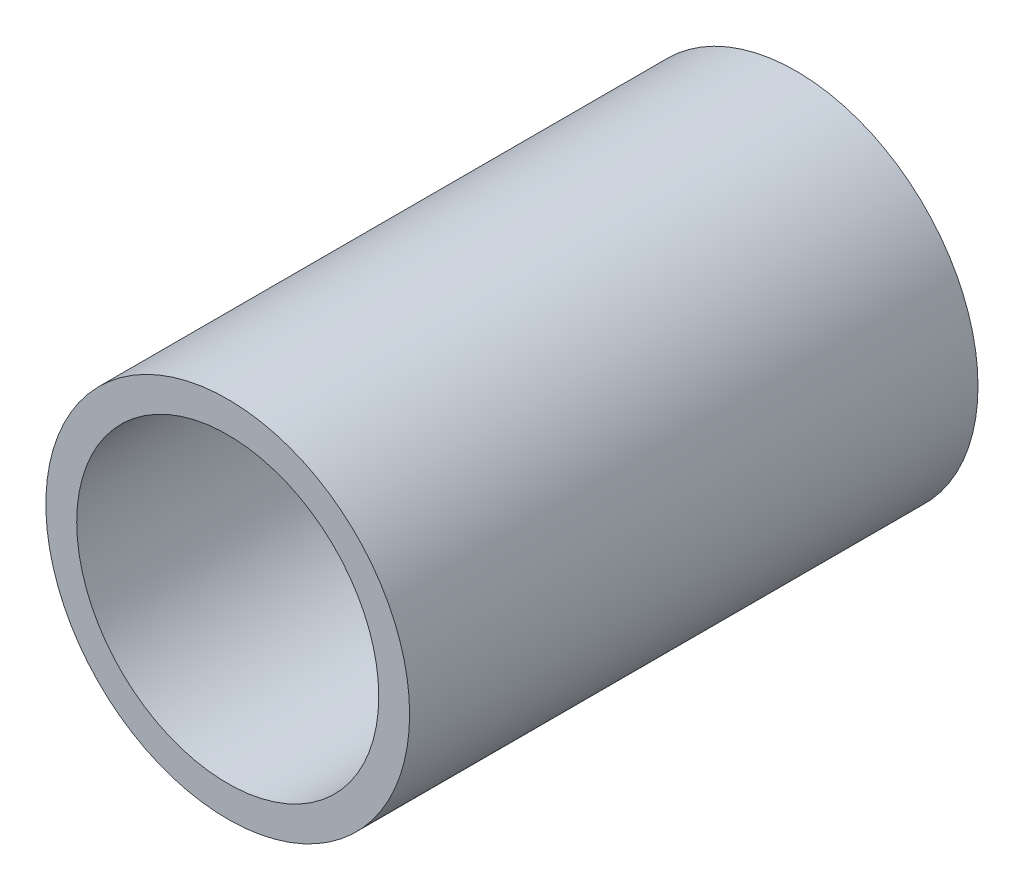
from build123d import *

# Parameters (mm, degrees)
SKETCH1_R           = 16
SKETCH1_R_2         = 13.28551995
BOSS_EXTRUDE1_DEPTH = 50


with BuildPart() as part:
    # Sketch1 → Boss-Extrude1 (new body)
    with BuildSketch(Plane.XY):
        Circle(SKETCH1_R)
        Circle(SKETCH1_R_2, mode=Mode.SUBTRACT)
    extrude(amount=BOSS_EXTRUDE1_DEPTH)


solid = part.part
